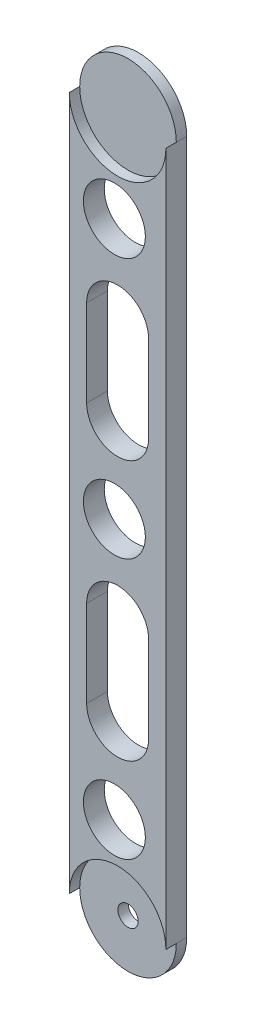
from build123d import *

# Parameters (mm, degrees)
ESQUISSE1_W             = 27.85
ESQUISSE1_H             = 200
BOSS_EXTRU_1_DEPTH      = 6
ESQUISSE2_R             = 13.925
ENL_V_MAT_EXTRU_1_DEPTH = 3
ESQUISSE3_R             = 2.925
ENL_V_MAT_EXTRU_2_DEPTH = 3
ESQUISSE5_R             = 13.925
ENL_V_MAT_EXTRU_3_DEPTH = 3
ESQUISSE6_R             = 8.925
ESQUISSE6_W             = 17.85
ESQUISSE6_H             = 25
ENL_V_MAT_EXTRU_4_DEPTH = 10


with BuildPart() as part:
    # Esquisse1 → Boss.-Extru.1 (new body)
    with BuildSketch(Plane.XY):
        with Locations((3.966452722, -72.813095238)):
            Rectangle(ESQUISSE1_W, ESQUISSE1_H)
        with BuildLine():
            Line((-9.958547278, -172.813095238), (17.891452722, -172.813095238))
            ThreePointArc((17.891452722, -172.813095238), (3.966452722, -186.738095238), (-9.958547278, -172.813095238))
        make_face()
        with BuildLine():
            Line((-9.958547278, 27.186904762), (17.891452722, 27.186904762))
            ThreePointArc((17.891452722, 27.186904762), (3.966452722, 41.111904762), (-9.958547278, 27.186904762))
        make_face()
    extrude(amount=BOSS_EXTRU_1_DEPTH)

    # Esquisse2 → Enlèv. mat.-Extru.1 (cut)
    with BuildSketch(Plane.XY.offset(6)):
        with Locations((3.966452722, -172.813095238)):
            Circle(ESQUISSE2_R)
    extrude(amount=-ENL_V_MAT_EXTRU_1_DEPTH, mode=Mode.SUBTRACT)

    # Esquisse3 → Enlèv. mat.-Extru.2 (cut)
    with BuildSketch(Plane.XY.offset(3)):
        with Locations((3.966452722, -172.813095238)):
            Circle(ESQUISSE3_R)
    extrude(amount=-ENL_V_MAT_EXTRU_2_DEPTH, mode=Mode.SUBTRACT)

    # Esquisse5 → Enlèv. mat.-Extru.3 (cut)
    with BuildSketch(Plane.XY.offset(6)):
        with Locations((3.966452722, 27.186904762)):
            Circle(ESQUISSE5_R)
    extrude(amount=-ENL_V_MAT_EXTRU_3_DEPTH, mode=Mode.SUBTRACT)

    # Esquisse6 → Enlèv. mat.-Extru.4 (cut)
    with BuildSketch(Plane(origin=(0, 0, 0), x_dir=(-1, 0, 0), z_dir=(0, 0, -1))):
        with Locations((-3.040571359, 2.186904762)):
            Circle(ESQUISSE6_R)
        with BuildLine():
            ThreePointArc((-12.891452722, -22.813095238), (-3.966452722, -13.888095238), (4.958547278, -22.813095238))
            Line((4.958547278, -22.813095238), (-12.891452722, -22.813095238))
        make_face()
        with Locations((-3.966452722, -35.313095238)):
            Rectangle(ESQUISSE6_W, ESQUISSE6_H)
        with BuildLine():
            ThreePointArc((4.958547278, -47.813095238), (-3.966452722, -56.738095238), (-12.891452722, -47.813095238))
            Line((-12.891452722, -47.813095238), (4.958547278, -47.813095238))
        make_face()
        with Locations((-3.040571359, -72.813095238)):
            Circle(ESQUISSE6_R)
        with Locations((-3.966452722, -110.313095238)):
            Rectangle(ESQUISSE6_W, ESQUISSE6_H)
        with BuildLine():
            ThreePointArc((-12.891452722, -97.813095238), (-3.966452722, -88.888095238), (4.958547278, -97.813095238))
            Line((4.958547278, -97.813095238), (-12.891452722, -97.813095238))
        make_face()
        with BuildLine():
            ThreePointArc((4.958547278, -122.813095238), (-3.966452722, -131.738095238), (-12.891452722, -122.813095238))
            Line((-12.891452722, -122.813095238), (4.958547278, -122.813095238))
        make_face()
        with Locations((-3.040571359, -147.813095238)):
            Circle(ESQUISSE6_R)
    extrude(amount=-ENL_V_MAT_EXTRU_4_DEPTH, mode=Mode.SUBTRACT)


solid = part.part
